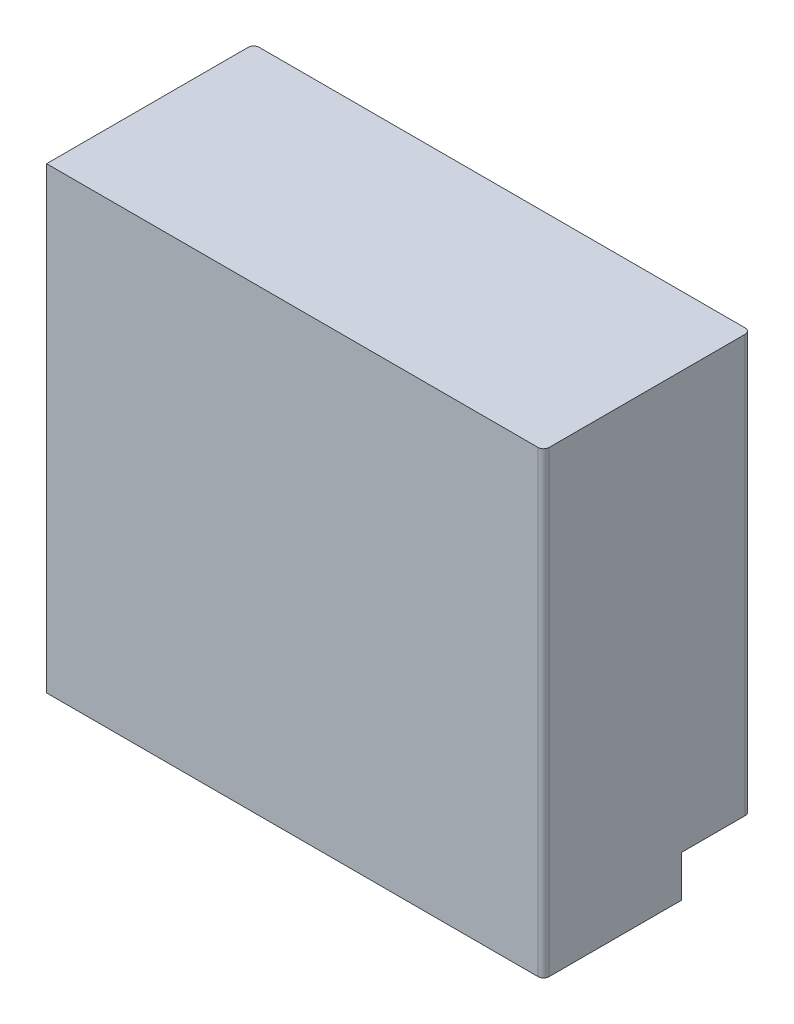
from build123d import *

# Parameters (mm, degrees)
SKETCH1_W           = 180
SKETCH1_H           = 75
BOSS_EXTRUDE1_DEPTH = 166
SKETCH2_W           = 50
SKETCH2_H           = 25
CUT_EXTRUDE1_DEPTH  = 15
FILLET1_R           = 2
SKETCH3_W           = 4
SKETCH3_H           = 15
BOSS_EXTRUDE2_DEPTH = 14
FILLET2_R           = 4


with BuildPart() as part:
    # Sketch1 → Boss-Extrude1 (new body)
    with BuildSketch(Plane(origin=(0, 0, 0), x_dir=(1, 0, 0), z_dir=(0, 1, 0))):
        Rectangle(SKETCH1_W, SKETCH1_H)
    extrude(amount=BOSS_EXTRUDE1_DEPTH)

    # Sketch2 → Cut-Extrude1 (cut)
    with BuildSketch(Plane.XZ):
        with Locations((-65, -25)):
            Rectangle(SKETCH2_W, SKETCH2_H)
        with Locations((65, -25)):
            Rectangle(SKETCH2_W, SKETCH2_H)
    extrude(amount=-CUT_EXTRUDE1_DEPTH, mode=Mode.SUBTRACT)

    # Fillet1
    fillet1_edges = [part.edges().sort_by_distance(p)[0] for p in [
        (0, 0, -37.5),
        (-90, 90.5, -37.5),
        (90, 90.5, -37.5),
        (90, 83, 37.5),
    ]]
    fillet(fillet1_edges, radius=FILLET1_R)

    # Sketch3 → Boss-Extrude2 (add)
    with BuildSketch(Plane.XZ.offset(-15)):
        with Locations((-72, -25)):
            Rectangle(SKETCH3_W, SKETCH3_H)
        with Locations((72, -25)):
            Rectangle(SKETCH3_W, SKETCH3_H)
    extrude(amount=BOSS_EXTRUDE2_DEPTH)

    # Fillet2
    fillet2_edges = [part.edges().sort_by_distance(p)[0] for p in [
        (-72, 1, -32.5),
        (-72, 1, -17.5),
        (72, 1, -17.5),
        (72, 1, -32.5),
    ]]
    fillet(fillet2_edges, radius=FILLET2_R)


solid = part.part
